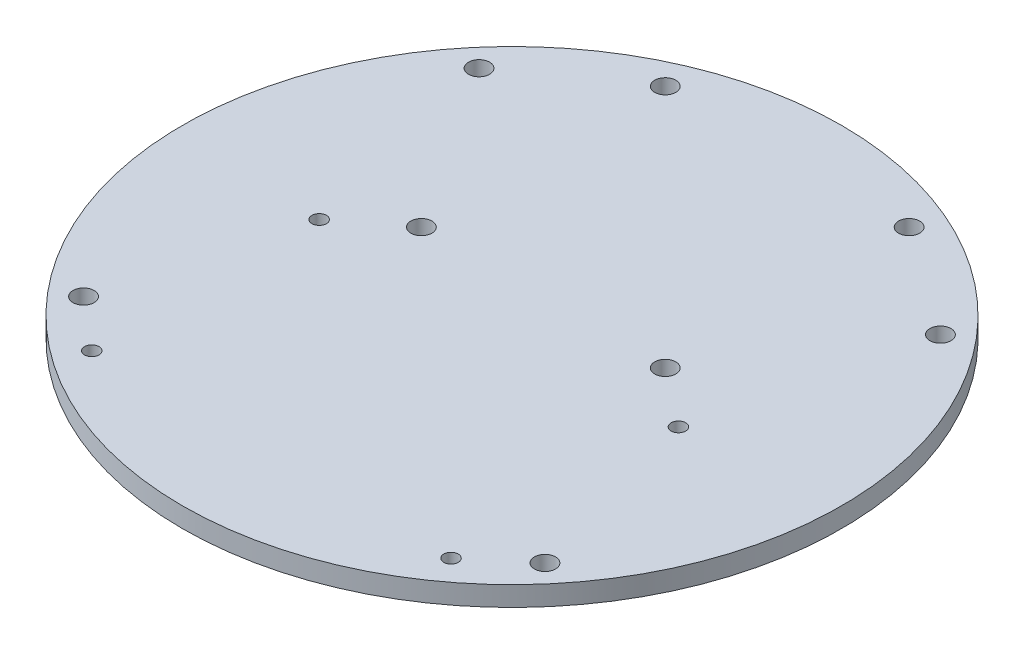
from build123d import *

# Parameters (mm, degrees)
SKETCH1_R           = 50
SKETCH1_R_2         = 1.1
SKETCH1_R_3         = 1.6
BOSS_EXTRUDE1_DEPTH = 3


with BuildPart() as part:
    # Sketch1 → Boss-Extrude1 (new body)
    with BuildSketch(Plane(origin=(0, 0, 0), x_dir=(1, 0, 0), z_dir=(0, 1, 0))):
        Circle(SKETCH1_R)
        with Locations((-27.25, -2)):
            Circle(SKETCH1_R_2, mode=Mode.SUBTRACT)
        with Locations((-27.25, -36.5)):
            Circle(SKETCH1_R_2, mode=Mode.SUBTRACT)
        with Locations((27.25, -2)):
            Circle(SKETCH1_R_2, mode=Mode.SUBTRACT)
        with Locations((27.25, -36.5)):
            Circle(SKETCH1_R_2, mode=Mode.SUBTRACT)
        with Locations((-18.5, 41.75)):
            Circle(SKETCH1_R_3, mode=Mode.SUBTRACT)
        with Locations((18.5, 41.75)):
            Circle(SKETCH1_R_3, mode=Mode.SUBTRACT)
        with Locations((18.5, 4.75)):
            Circle(SKETCH1_R_3, mode=Mode.SUBTRACT)
        with Locations((-18.5, 4.75)):
            Circle(SKETCH1_R_3, mode=Mode.SUBTRACT)
        with Locations((-35, -30)):
            Circle(SKETCH1_R_3, mode=Mode.SUBTRACT)
        with Locations((-35, 30)):
            Circle(SKETCH1_R_3, mode=Mode.SUBTRACT)
        with Locations((35, -30)):
            Circle(SKETCH1_R_3, mode=Mode.SUBTRACT)
        with Locations((35, 30)):
            Circle(SKETCH1_R_3, mode=Mode.SUBTRACT)
    extrude(amount=BOSS_EXTRUDE1_DEPTH)


solid = part.part
